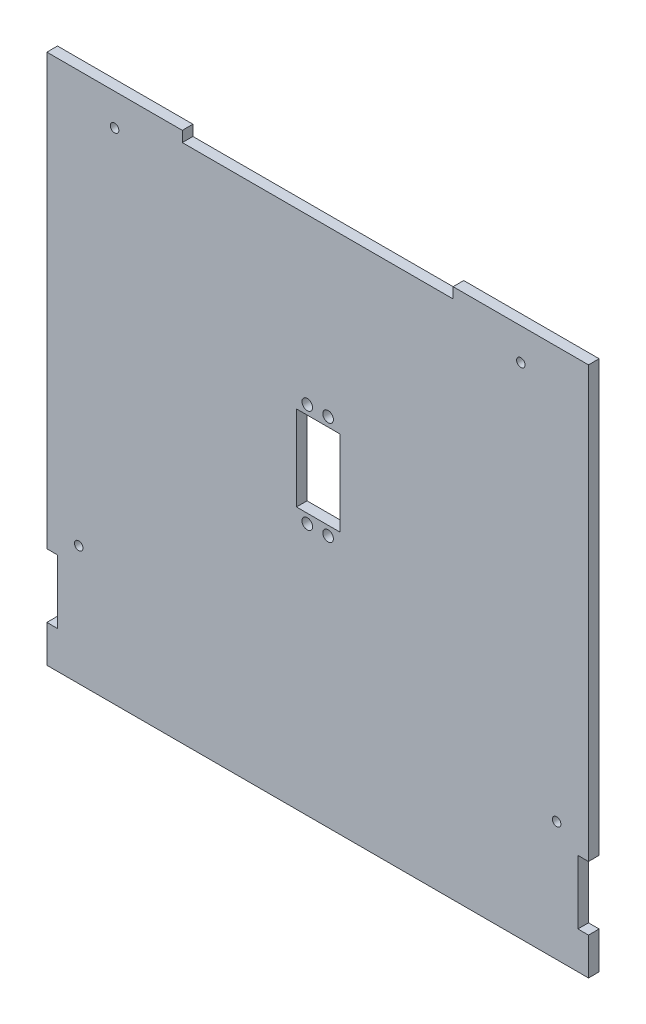
from build123d import *

# Parameters (mm, degrees)
SKETCH2_W               = 255
SKETCH2_H               = 250
BOSS_EXTRUDE1_DEPTH     = 5
SKETCH4_W               = 20
SKETCH4_H               = 54.5
CUT_EXTRUDE1_DEPTH      = 32
CUT_EXTRUDE1_DEPTH_BACK = 23
SKETCH5_W               = 20
SKETCH5_H               = 7.25
BOSS_EXTRUDE3_DEPTH     = 5
CUT_EXTRUDE2_DEPTH      = 23
SKETCH7_R               = 2.5
CUT_EXTRUDE3_DEPTH      = 23
BOSS_EXTRUDE6_DEPTH     = 5
SKETCH9_W               = 0.5
SKETCH9_H               = 0.5
BOSS_EXTRUDE7_DEPTH     = 5
SKETCH10_W              = 6
SKETCH10_H              = 65
BOSS_EXTRUDE8_DEPTH     = 5
SKETCH10_3_W            = 5
SKETCH10_3_H            = 30
CUT_EXTRUDE4_DEPTH      = 10
SKETCH11_W              = 6
SKETCH11_H              = 185
BOSS_EXTRUDE9_DEPTH     = 5
SKETCH14_W              = 6
SKETCH14_H              = 250
CUT_EXTRUDE5_DEPTH      = 10
CUT_EXTRUDE6_DEPTH      = 185
SKETCH16_R              = 1.5
CUT_EXTRUDE7_DEPTH      = 185
SKETCH17_R              = 1.5
CUT_EXTRUDE8_DEPTH      = 185
SKETCH18_R              = 2
CUT_EXTRUDE9_DEPTH      = 10


with BuildPart() as part:
    # Sketch2 → Boss-Extrude1 (new body)
    with BuildSketch(Plane.XY):
        with Locations((-2.5, 0)):
            Rectangle(SKETCH2_W, SKETCH2_H)
    extrude(amount=BOSS_EXTRUDE1_DEPTH)

    # Sketch4 → Cut-Extrude1 (cut, two sides)
    with BuildSketch(Plane(origin=(0, 0, 0), x_dir=(-1, 0, 0), z_dir=(0, 0, -1))) as cut_extrude1_sk:
        with Locations((2.5, 18.3)):
            Rectangle(SKETCH4_W, SKETCH4_H)
    extrude(amount=CUT_EXTRUDE1_DEPTH, mode=Mode.SUBTRACT)
    extrude(cut_extrude1_sk.sketch, amount=-CUT_EXTRUDE1_DEPTH_BACK, mode=Mode.SUBTRACT)

    # Sketch5 → Boss-Extrude3 (add)
    with BuildSketch(Plane(origin=(0, 0, 0), x_dir=(-1, 0, 0), z_dir=(0, 0, -1))):
        with Locations((2.5, 41.925)):
            Rectangle(SKETCH5_W, SKETCH5_H)
        with Locations((2.5, -5.325)):
            Rectangle(SKETCH5_W, SKETCH5_H)
    extrude(amount=-BOSS_EXTRUDE3_DEPTH)

    # Sketch6 → Cut-Extrude2 (cut)
    with BuildSketch(Plane(origin=(0, 0, 0), x_dir=(-1, 0, 0), z_dir=(0, 0, -1))):
        Polygon((-7.5, 38.3), (-7.5, 48.3), (-32.5, 48.3), (-32.5, -11.7), (-7.5, -11.7), (-7.5, -1.7), align=None)
    extrude(amount=-CUT_EXTRUDE2_DEPTH, mode=Mode.SUBTRACT)

    # Sketch7 → Cut-Extrude3 (cut)
    with BuildSketch(Plane(origin=(0, 0, 0), x_dir=(-1, 0, 0), z_dir=(0, 0, -1))):
        with Locations((-2.4, 42.6)):
            Circle(SKETCH7_R)
        with Locations((7.4, 42.6)):
            Circle(SKETCH7_R)
        with Locations((-2.4, -6)):
            Circle(SKETCH7_R)
        with Locations((7.4, -6)):
            Circle(SKETCH7_R)
    extrude(amount=-CUT_EXTRUDE3_DEPTH, mode=Mode.SUBTRACT)

    # Sketch8 → Boss-Extrude6 (add)
    with BuildSketch(Plane(origin=(0, 0, 0), x_dir=(-1, 0, 0), z_dir=(0, 0, -1))):
        Polygon((-8, 38.8), (-7.5, 38.8), (-7.5, 48.3), (-32.5, 48.3), (-32.5, -11.7), (-7.5, -11.7), (-7.5, -2.2), (-8, -2.2), align=None)
    extrude(amount=-BOSS_EXTRUDE6_DEPTH)

    # Sketch9 → Boss-Extrude7 (add)
    with BuildSketch(Plane(origin=(0, 0, 0), x_dir=(-1, 0, 0), z_dir=(0, 0, -1))):
        with Locations((-7.75, 38.55)):
            Rectangle(SKETCH9_W, SKETCH9_H)
        with Locations((-7.75, -1.95)):
            Rectangle(SKETCH9_W, SKETCH9_H)
    extrude(amount=-BOSS_EXTRUDE7_DEPTH)

    # Sketch10 → Boss-Extrude8 (add)
    with BuildSketch(Plane(origin=(0, 0, 0), x_dir=(-1, 0, 0), z_dir=(0, 0, -1))):
        Polygon((130, -107.5), (130, -125), (136, -125), (136, -60), (130, -60), (130, -77.5), align=None)
        with Locations((-128, -92.5)):
            Rectangle(SKETCH10_W, SKETCH10_H)
    extrude(amount=-BOSS_EXTRUDE8_DEPTH)

    # Sketch10_3 → Cut-Extrude4 (cut)
    with BuildSketch(Plane(origin=(0, 0, 0), x_dir=(-1, 0, 0), z_dir=(0, 0, -1))):
        with Locations((127.5, -92.5)):
            Rectangle(SKETCH10_3_W, SKETCH10_3_H)
        with Locations((-122.5, -92.5)):
            Rectangle(SKETCH10_3_W, SKETCH10_3_H)
    extrude(amount=-CUT_EXTRUDE4_DEPTH, mode=Mode.SUBTRACT)

    # Sketch11 → Boss-Extrude9 (add)
    with BuildSketch(Plane(origin=(0, 0, 0), x_dir=(-1, 0, 0), z_dir=(0, 0, -1))):
        with Locations((-128, 32.5)):
            Rectangle(SKETCH11_W, SKETCH11_H)
        with Locations((133, 32.5)):
            Rectangle(SKETCH11_W, SKETCH11_H)
    extrude(amount=-BOSS_EXTRUDE9_DEPTH)

    # Sketch14 → Cut-Extrude5 (cut)
    with BuildSketch(Plane(origin=(0, 0, 0), x_dir=(-1, 0, 0), z_dir=(0, 0, -1))):
        with Locations((-128, 0)):
            Rectangle(SKETCH14_W, SKETCH14_H)
        with Locations((133, 0)):
            Rectangle(SKETCH14_W, SKETCH14_H)
    extrude(amount=-CUT_EXTRUDE5_DEPTH, mode=Mode.SUBTRACT)

    # Sketch15 → Cut-Extrude6 (cut)
    with BuildSketch(Plane(origin=(0, 0, 0), x_dir=(-1, 0, 0), z_dir=(0, 0, -1))):
        Polygon((2.5, 125), (-61.25, 125), (-61.25, 120), (2.5, 120), (66.25, 120), (66.25, 125), align=None)
    extrude(amount=-CUT_EXTRUDE6_DEPTH, mode=Mode.SUBTRACT)

    # Sketch16 → Cut-Extrude7 (cut)
    with BuildSketch(Plane(origin=(0, 0, 0), x_dir=(-1, 0, 0), z_dir=(0, 0, -1))):
        with Locations((-93.125, 110)):
            Circle(SKETCH16_R)
        with Locations((98.125, 110)):
            Circle(SKETCH16_R)
    extrude(amount=-CUT_EXTRUDE7_DEPTH, mode=Mode.SUBTRACT)

    # Sketch17 → Cut-Extrude8 (cut)
    with BuildSketch(Plane(origin=(0, 0, 0), x_dir=(-1, 0, 0), z_dir=(0, 0, -1))):
        with Locations((-110, -68.75)):
            Circle(SKETCH17_R)
        with Locations((115, -68.75)):
            Circle(SKETCH17_R)
    extrude(amount=-CUT_EXTRUDE8_DEPTH, mode=Mode.SUBTRACT)

    # Sketch18 → Cut-Extrude9 (cut)
    with BuildSketch(Plane(origin=(0, 0, 0), x_dir=(-1, 0, 0), z_dir=(0, 0, -1))):
        with Locations((-93.125, 110)):
            Circle(SKETCH18_R)
        with Locations((98.125, 110)):
            Circle(SKETCH18_R)
        with Locations((115, -68.75)):
            Circle(SKETCH18_R)
        with Locations((-110, -68.75)):
            Circle(SKETCH18_R)
    extrude(amount=-CUT_EXTRUDE9_DEPTH, mode=Mode.SUBTRACT)


solid = part.part
